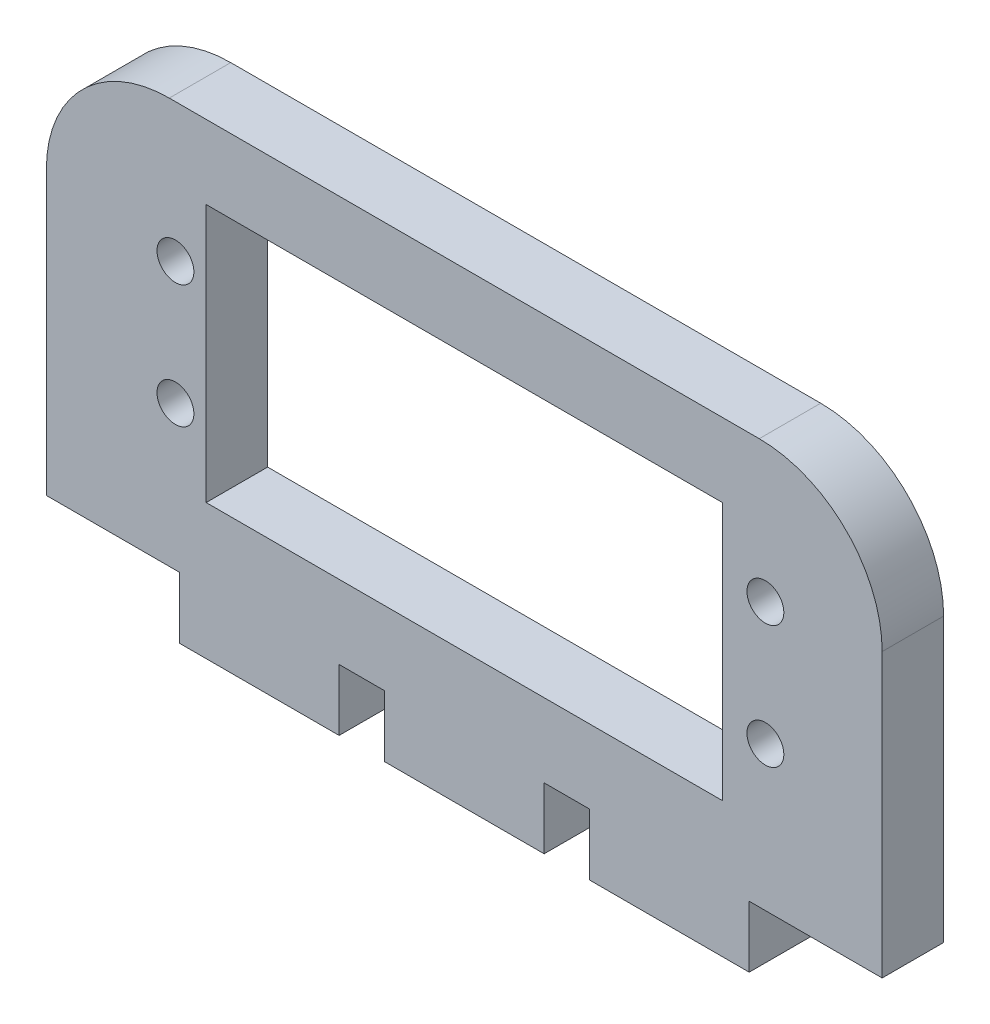
from build123d import *

# Parameters (mm, degrees)
SKETCH1_R           = 1.5
SKETCH1_W           = 42
SKETCH1_H           = 21
BOSS_EXTRUDE1_DEPTH = 5
FILLET2_R           = 10
FILLET3_R           = 10


with BuildPart() as part:
    # Sketch1 → Boss-Extrude1 (new body)
    with BuildSketch(Plane.XY):
        Polygon((-28.086956522, 0), (-17.269090954, 0), (-17.269090954, -5), (-4.269090954, -5), (-4.269090954, 0), (-0.586956522, 0), (-0.586956522, -5), (12.413043478, -5), (12.413043478, 0), (16.095177911, 0), (16.095177911, -5), (29.095177911, -5), (29.095177911, 0), (39.913043478, 0), (39.913043478, 33), (-28.086956522, 33), align=None)
        with Locations((30.413043478, 21.75)):
            Circle(SKETCH1_R, mode=Mode.SUBTRACT)
        with Locations((30.413043478, 11.75)):
            Circle(SKETCH1_R, mode=Mode.SUBTRACT)
        with Locations((-17.586956522, 21.75)):
            Circle(SKETCH1_R, mode=Mode.SUBTRACT)
        with Locations((-17.586956522, 11.75)):
            Circle(SKETCH1_R, mode=Mode.SUBTRACT)
        with Locations((5.913043478, 16.5)):
            Rectangle(SKETCH1_W, SKETCH1_H, mode=Mode.SUBTRACT)
    extrude(amount=BOSS_EXTRUDE1_DEPTH)

    # Fillet2
    fillet2_edges = [part.edges().sort_by_distance(p)[0] for p in [
        (-28.086956522, 33, 2.5),
    ]]
    fillet(fillet2_edges, radius=FILLET2_R)

    # Fillet3
    fillet3_edges = [part.edges().sort_by_distance(p)[0] for p in [
        (39.913043478, 33, 2.5),
    ]]
    fillet(fillet3_edges, radius=FILLET3_R)


solid = part.part
